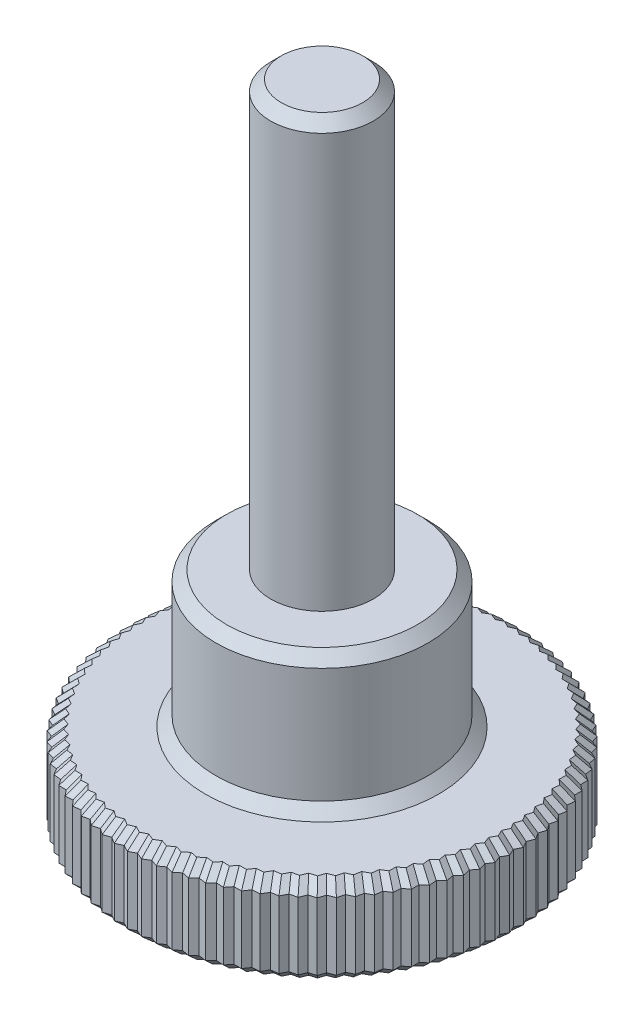
from build123d import *

# Parameters (mm, degrees)
EXTRUDE1_DEPTH = 2.5
SKETCH2_R      = 3
EXTRUDE2_DEPTH = 3.85
SKETCH3_R      = 1.45
EXTRUDE3_DEPTH = 12
CHAMFER1_SIZE  = 0.3


with BuildPart() as part:
    # Sketch1 → Extrude1 (new body)
    with BuildSketch(Plane(origin=(0, 0, 0), x_dir=(1, 0, 0), z_dir=(0, 1, 0))):
        Polygon((0, 5.5), (0.188676261, 5.402981197), (0.383660606, 5.486602276), (0.565109571, 5.376658415), (0.765452055, 5.446474378), (0.938789724, 5.324141095), (1.143514299, 5.379811804), (1.307896188, 5.245685094), (1.516005457, 5.286939328), (1.670630713, 5.141672643), (1.881110788, 5.168309414), (2.025226093, 5.012610479), (2.237051537, 5.024500017), (2.369954776, 4.859127381), (2.582093595, 4.856211761), (2.703137277, 4.681971103), (2.914555953, 4.664264529), (3.023150364, 4.482004732), (3.232818888, 4.449593469), (3.328434967, 4.260202485), (3.535331853, 4.213244437), (3.61750377, 4.017644959), (3.820621038, 3.956368902), (3.888948458, 3.755513871), (4.08729654, 3.680218335), (4.141446579, 3.475086297), (4.334059145, 3.386138114), (4.37376799, 3.177728452), (4.559706649, 3.075560969), (4.584780842, 2.864889033), (4.763139721, 2.75), (4.773457103, 2.538092163), (4.943367255, 2.411041307), (4.938877561, 2.198929963), (5.0995112, 2.060336264), (5.080236303, 1.849054797), (5.23081084, 1.699593469), (5.196844646, 1.490171223), (5.336626495, 1.330570426), (5.288134483, 1.124027683), (5.416442642, 0.955064977), (5.353661061, 0.752407994), (5.469870425, 0.574906548), (5.39310514, 0.377122649), (5.496649549, 0.191947232), (5.406274553, 0), (5.496649549, -0.191947232), (5.39310514, -0.377122649), (5.469870425, -0.574906548), (5.353661061, -0.752407994), (5.416442642, -0.955064977), (5.288134483, -1.124027683), (5.336626495, -1.330570426), (5.196844646, -1.490171223), (5.23081084, -1.699593469), (5.080236303, -1.849054797), (5.0995112, -2.060336264), (4.938877561, -2.198929963), (4.943367255, -2.411041307), (4.773457103, -2.538092163), (4.763139721, -2.75), (4.584780842, -2.864889033), (4.559706649, -3.075560969), (4.37376799, -3.177728452), (4.334059145, -3.386138114), (4.141446579, -3.475086297), (4.08729654, -3.680218335), (3.888948458, -3.755513871), (3.820621038, -3.956368902), (3.61750377, -4.017644959), (3.535331853, -4.213244437), (3.328434967, -4.260202485), (3.232818888, -4.449593469), (3.023150364, -4.482004732), (2.914555953, -4.664264529), (2.703137277, -4.681971103), (2.582093595, -4.856211761), (2.369954776, -4.859127381), (2.237051537, -5.024500017), (2.025226093, -5.012610479), (1.881110788, -5.168309414), (1.670630713, -5.141672643), (1.516005457, -5.286939328), (1.307896188, -5.245685094), (1.143514299, -5.379811804), (0.938789724, -5.324141095), (0.765452055, -5.446474378), (0.565109571, -5.376658415), (0.383660606, -5.486602276), (0.188676261, -5.402981197), (0, -5.5), (-0.188676261, -5.402981197), (-0.383660606, -5.486602276), (-0.565109571, -5.376658415), (-0.765452055, -5.446474378), (-0.938789724, -5.324141095), (-1.143514299, -5.379811804), (-1.307896188, -5.245685094), (-1.516005457, -5.286939328), (-1.670630713, -5.141672643), (-1.881110788, -5.168309414), (-2.025226093, -5.012610479), (-2.237051537, -5.024500017), (-2.369954776, -4.859127381), (-2.582093595, -4.856211761), (-2.703137277, -4.681971103), (-2.914555953, -4.664264529), (-3.023150364, -4.482004732), (-3.232818888, -4.449593469), (-3.328434967, -4.260202485), (-3.535331853, -4.213244437), (-3.61750377, -4.017644959), (-3.820621038, -3.956368902), (-3.888948458, -3.755513871), (-4.08729654, -3.680218335), (-4.141446579, -3.475086297), (-4.334059145, -3.386138114), (-4.37376799, -3.177728452), (-4.559706649, -3.075560969), (-4.584780842, -2.864889033), (-4.763139721, -2.75), (-4.773457103, -2.538092163), (-4.943367255, -2.411041307), (-4.938877561, -2.198929963), (-5.0995112, -2.060336264), (-5.080236303, -1.849054797), (-5.23081084, -1.699593469), (-5.196844646, -1.490171223), (-5.336626495, -1.330570426), (-5.288134483, -1.124027683), (-5.416442642, -0.955064977), (-5.353661061, -0.752407994), (-5.469870425, -0.574906548), (-5.39310514, -0.377122649), (-5.496649549, -0.191947232), (-5.406274553, 0), (-5.496649549, 0.191947232), (-5.39310514, 0.377122649), (-5.469870425, 0.574906548), (-5.353661061, 0.752407994), (-5.416442642, 0.955064977), (-5.288134483, 1.124027683), (-5.336626495, 1.330570426), (-5.196844646, 1.490171223), (-5.23081084, 1.699593469), (-5.080236303, 1.849054797), (-5.0995112, 2.060336264), (-4.938877561, 2.198929963), (-4.943367255, 2.411041307), (-4.773457103, 2.538092163), (-4.763139721, 2.75), (-4.584780842, 2.864889033), (-4.559706649, 3.075560969), (-4.37376799, 3.177728452), (-4.334059145, 3.386138114), (-4.141446579, 3.475086297), (-4.08729654, 3.680218335), (-3.888948458, 3.755513871), (-3.820621038, 3.956368902), (-3.61750377, 4.017644959), (-3.535331853, 4.213244437), (-3.328434967, 4.260202485), (-3.232818888, 4.449593469), (-3.023150364, 4.482004732), (-2.914555953, 4.664264529), (-2.703137277, 4.681971103), (-2.582093595, 4.856211761), (-2.369954776, 4.859127381), (-2.237051537, 5.024500017), (-2.025226093, 5.012610479), (-1.881110788, 5.168309414), (-1.670630713, 5.141672643), (-1.516005457, 5.286939328), (-1.307896188, 5.245685094), (-1.143514299, 5.379811804), (-0.938789724, 5.324141095), (-0.765452055, 5.446474378), (-0.565109571, 5.376658415), (-0.383660606, 5.486602276), (-0.188676261, 5.402981197), align=None)
    extrude(amount=EXTRUDE1_DEPTH)

    # Sketch2 → Extrude2 (add)
    with BuildSketch(Plane(origin=(0, 2.5, 0), x_dir=(1, 0, 0), z_dir=(0, 1, 0))):
        Circle(SKETCH2_R)
    extrude(amount=EXTRUDE2_DEPTH)

    # Sketch3 → Extrude3 (add)
    with BuildSketch(Plane(origin=(0, 6.35, 0), x_dir=(1, 0, 0), z_dir=(0, 1, 0))):
        Circle(SKETCH3_R)
    extrude(amount=EXTRUDE3_DEPTH)

    # Chamfer1
    chamfer1_edges = [part.edges().sort_by_distance(p)[0] for p in [
        (-3.280626927, 2.5, -4.354897977),
        (-3.43188341, 2.5, -4.236723461),
        (-0.09433813, 2.5, -5.451490598),
        (-3.576417812, 2.5, -4.115444698),
        (-3.719062404, 2.5, -3.987006931),
        (-3.854784748, 2.5, -3.855941387),
        (-3.988122499, 2.5, -3.717866103),
        (-4.11437156, 2.5, -3.577652316),
        (-4.237752862, 2.5, -3.430612206),
        (-4.353913567, 2.5, -3.281933283),
        (-4.466737319, 2.5, -3.126644711),
        (-4.572243746, 2.5, -2.970225001),
        (-4.673960281, 2.5, -2.807444517),
        (-0.286168433, 2.5, -5.444791737),
        (-4.768298412, 2.5, -2.644046082),
        (-4.858412179, 2.5, -2.474566735),
        (-4.941122408, 2.5, -2.304985635),
        (-5.01919438, 2.5, -2.129633114),
        (-5.089873752, 2.5, -1.954695531),
        (0.286168433, 0, -5.444791737),
        (0.474385088, 0, -5.431630346),
        (0.665280813, 0, -5.411566397),
        (0.85212089, 0, -5.385307736),
        (1.041152012, 0, -5.351976449),
        (1.225705244, 0, -5.312748449),
        (1.411950822, 0, -5.266312211),
        (1.593318085, 0, -5.214305985),
        (1.775870751, 0, -5.154991028),
        (-5.155523572, 2.5, -1.774324133),
        (1.953168441, 0, -5.090459947),
        (2.131138815, 0, -5.018555248),
        (2.303503156, 0, -4.941813699),
        (2.476024185, 0, -4.857669571),
        (2.642615436, 0, -4.769091432),
        (2.808846615, 0, -4.673117816),
        (2.968853159, 0, -4.57313463),
        (3.127984626, 0, -4.465799101),
        (3.280626927, 0, -4.354897977),
        (3.43188341, 0, -4.236723461),
        (-5.213827743, 2.5, -1.594882346),
        (3.576417812, 0, -4.115444698),
        (3.719062404, 0, -3.987006931),
        (3.854784748, 0, -3.855941387),
        (3.988122499, 0, -3.717866103),
        (4.11437156, 0, -3.577652316),
        (4.237752862, 0, -3.430612206),
        (4.353913567, 0, -3.281933283),
        (4.466737319, 0, -3.126644711),
        (4.572243746, 0, -2.970225001),
        (4.673960281, 0, -2.807444517),
        (-5.26673557, 2.5, -1.410370824),
        (4.768298412, 0, -2.644046082),
        (4.858412179, 0, -2.474566735),
        (4.941122408, 0, -2.304985635),
        (5.01919438, 0, -2.129633114),
        (5.089873752, 0, -1.954695531),
        (5.155523572, 0, -1.774324133),
        (5.213827743, 0, -1.594882346),
        (5.26673557, 0, -1.410370824),
        (5.312380489, 0, -1.227299055),
        (5.352288562, 0, -1.03954633),
        (-5.312380489, 2.5, -1.227299055),
        (5.385051851, 0, -0.853736486),
        (5.411765743, 0, -0.663657271),
        (5.431487782, 0, -0.476014598),
        (5.444877344, 0, -0.28453494),
        (5.451462051, 0, -0.095973616),
        (5.451462051, 0, 0.095973616),
        (5.444877344, 0, 0.28453494),
        (5.431487782, 0, 0.476014598),
        (5.411765743, 0, 0.663657271),
        (5.385051851, 0, 0.853736486),
        (-5.352288562, 2.5, -1.03954633),
        (5.352288562, 0, 1.03954633),
        (5.312380489, 0, 1.227299055),
        (5.26673557, 0, 1.410370824),
        (5.213827743, 0, 1.594882346),
        (5.155523572, 0, 1.774324133),
        (5.089873752, 0, 1.954695531),
        (5.01919438, 0, 2.129633114),
        (4.941122408, 0, 2.304985635),
        (-0.474385088, 2.5, -5.431630346),
        (4.858412179, 0, 2.474566735),
        (4.768298412, 0, 2.644046082),
        (-5.385051851, 2.5, -0.853736486),
        (4.673960281, 0, 2.807444517),
        (4.572243746, 0, 2.970225001),
        (4.466737319, 0, 3.126644711),
        (4.353913567, 0, 3.281933283),
        (4.237752862, 0, 3.430612206),
        (4.11437156, 0, 3.577652316),
        (3.988122499, 0, 3.717866103),
        (3.854784748, 0, 3.855941387),
        (3.719062404, 0, 3.987006931),
        (3.576417812, 0, 4.115444698),
        (-5.411765743, 2.5, -0.663657271),
        (3.43188341, 0, 4.236723461),
        (3.280626927, 0, 4.354897977),
        (3.127984626, 0, 4.465799101),
        (2.968853159, 0, 4.57313463),
        (2.808846615, 0, 4.673117816),
        (2.642615436, 0, 4.769091432),
        (2.476024185, 0, 4.857669571),
        (2.303503156, 0, 4.941813699),
        (2.131138815, 0, 5.018555248),
        (1.953168441, 0, 5.090459947),
        (-5.431487782, 2.5, -0.476014598),
        (1.775870751, 0, 5.154991028),
        (1.593318085, 0, 5.214305985),
        (1.411950822, 0, 5.266312211),
        (1.225705244, 0, 5.312748449),
        (1.041152012, 0, 5.351976449),
        (0.85212089, 0, 5.385307736),
        (0.665280813, 0, 5.411566397),
        (0.474385088, 0, 5.431630346),
        (0.286168433, 0, 5.444791737),
        (0.09433813, 0, 5.451490598),
        (-5.444877344, 2.5, -0.28453494),
        (-0.09433813, 0, 5.451490598),
        (-0.286168433, 0, 5.444791737),
        (-0.474385088, 0, 5.431630346),
        (-0.665280813, 0, 5.411566397),
        (-0.85212089, 0, 5.385307736),
        (-1.041152012, 0, 5.351976449),
        (-1.225705244, 0, 5.312748449),
        (-1.411950822, 0, 5.266312211),
        (-1.593318085, 0, 5.214305985),
        (-1.775870751, 0, 5.154991028),
        (-5.451462051, 2.5, -0.095973616),
        (-1.953168441, 0, 5.090459947),
        (-2.131138815, 0, 5.018555248),
        (-2.303503156, 0, 4.941813699),
        (-2.476024185, 0, 4.857669571),
        (-2.642615436, 0, 4.769091432),
        (-2.808846615, 0, 4.673117816),
        (-2.968853159, 0, 4.57313463),
        (-3.127984626, 0, 4.465799101),
        (-3.280626927, 0, 4.354897977),
        (-3.43188341, 0, 4.236723461),
        (-5.451462051, 2.5, 0.095973616),
        (-3.576417812, 0, 4.115444698),
        (-3.719062404, 0, 3.987006931),
        (-3.854784748, 0, 3.855941387),
        (-3.988122499, 0, 3.717866103),
        (-4.11437156, 0, 3.577652316),
        (-4.237752862, 0, 3.430612206),
        (-4.353913567, 0, 3.281933283),
        (-4.466737319, 0, 3.126644711),
        (-4.572243746, 0, 2.970225001),
        (-4.673960281, 0, 2.807444517),
        (-5.444877344, 2.5, 0.28453494),
        (-4.768298412, 0, 2.644046082),
        (-4.858412179, 0, 2.474566735),
        (-4.941122408, 0, 2.304985635),
        (-5.01919438, 0, 2.129633114),
        (-5.089873752, 0, 1.954695531),
        (-5.155523572, 0, 1.774324133),
        (-5.213827743, 0, 1.594882346),
        (-5.26673557, 0, 1.410370824),
        (-5.312380489, 0, 1.227299055),
        (-5.352288562, 0, 1.03954633),
        (-5.431487782, 2.5, 0.476014598),
        (-5.385051851, 0, 0.853736486),
        (-5.411765743, 0, 0.663657271),
        (-5.431487782, 0, 0.476014598),
        (-5.444877344, 0, 0.28453494),
        (-5.451462051, 0, 0.095973616),
        (-5.451462051, 0, -0.095973616),
        (-5.444877344, 0, -0.28453494),
        (-5.431487782, 0, -0.476014598),
        (-5.411765743, 0, -0.663657271),
        (-5.385051851, 0, -0.853736486),
        (-5.411765743, 2.5, 0.663657271),
        (-5.352288562, 0, -1.03954633),
        (-5.312380489, 0, -1.227299055),
        (-5.26673557, 0, -1.410370824),
        (-5.213827743, 0, -1.594882346),
        (-5.155523572, 0, -1.774324133),
        (-5.089873752, 0, -1.954695531),
        (-5.01919438, 0, -2.129633114),
        (-4.941122408, 0, -2.304985635),
        (-4.858412179, 0, -2.474566735),
        (-4.768298412, 0, -2.644046082),
        (-5.385051851, 2.5, 0.853736486),
        (-4.673960281, 0, -2.807444517),
        (-4.572243746, 0, -2.970225001),
        (-4.466737319, 0, -3.126644711),
        (-4.353913567, 0, -3.281933283),
        (-4.237752862, 0, -3.430612206),
        (-4.11437156, 0, -3.577652316),
        (-3.988122499, 0, -3.717866103),
        (-3.854784748, 0, -3.855941387),
        (-0.665280813, 2.5, -5.411566397),
        (-3.719062404, 0, -3.987006931),
        (-3.576417812, 0, -4.115444698),
        (-5.352288562, 2.5, 1.03954633),
        (-3.43188341, 0, -4.236723461),
        (-3.280626927, 0, -4.354897977),
        (-3.127984626, 0, -4.465799101),
        (-2.968853159, 0, -4.57313463),
        (-2.808846615, 0, -4.673117816),
        (-2.642615436, 0, -4.769091432),
        (-2.476024185, 0, -4.857669571),
        (-2.303503156, 0, -4.941813699),
        (-2.131138815, 0, -5.018555248),
        (-1.953168441, 0, -5.090459947),
        (-5.312380489, 2.5, 1.227299055),
        (-1.775870751, 0, -5.154991028),
        (-1.593318085, 0, -5.214305985),
        (-1.411950822, 0, -5.266312211),
        (-1.225705244, 0, -5.312748449),
        (-1.041152012, 0, -5.351976449),
        (-0.85212089, 0, -5.385307736),
        (-0.665280813, 0, -5.411566397),
        (-0.474385088, 0, -5.431630346),
        (-0.286168433, 0, -5.444791737),
        (-0.09433813, 0, -5.451490598),
        (-5.26673557, 2.5, 1.410370824),
        (0.09433813, 0, -5.451490598),
        (-5.213827743, 2.5, 1.594882346),
        (-5.155523572, 2.5, 1.774324133),
        (-5.089873752, 2.5, 1.954695531),
        (-5.01919438, 2.5, 2.129633114),
        (-4.941122408, 2.5, 2.304985635),
        (-4.858412179, 2.5, 2.474566735),
        (-4.768298412, 2.5, 2.644046082),
        (-0.85212089, 2.5, -5.385307736),
        (-4.673960281, 2.5, 2.807444517),
        (-4.572243746, 2.5, 2.970225001),
        (-4.466737319, 2.5, 3.126644711),
        (-4.353913567, 2.5, 3.281933283),
        (-4.237752862, 2.5, 3.430612206),
        (-4.11437156, 2.5, 3.577652316),
        (-3.988122499, 2.5, 3.717866103),
        (-3.854784748, 2.5, 3.855941387),
        (-3.719062404, 2.5, 3.987006931),
        (-3.576417812, 2.5, 4.115444698),
        (-1.041152012, 2.5, -5.351976449),
        (-3.43188341, 2.5, 4.236723461),
        (-3.280626927, 2.5, 4.354897977),
        (-3.127984626, 2.5, 4.465799101),
        (-2.968853159, 2.5, 4.57313463),
        (-2.808846615, 2.5, 4.673117816),
        (-2.642615436, 2.5, 4.769091432),
        (-2.476024185, 2.5, 4.857669571),
        (-2.303503156, 2.5, 4.941813699),
        (-2.131138815, 2.5, 5.018555248),
        (-1.953168441, 2.5, 5.090459947),
        (-1.225705244, 2.5, -5.312748449),
        (-1.775870751, 2.5, 5.154991028),
        (-1.593318085, 2.5, 5.214305985),
        (-1.411950822, 2.5, 5.266312211),
        (-1.225705244, 2.5, 5.312748449),
        (-1.041152012, 2.5, 5.351976449),
        (-0.85212089, 2.5, 5.385307736),
        (-0.665280813, 2.5, 5.411566397),
        (-0.474385088, 2.5, 5.431630346),
        (-0.286168433, 2.5, 5.444791737),
        (-0.09433813, 2.5, 5.451490598),
        (-1.411950822, 2.5, -5.266312211),
        (0.09433813, 2.5, 5.451490598),
        (0.286168433, 2.5, 5.444791737),
        (0.474385088, 2.5, 5.431630346),
        (0.665280813, 2.5, 5.411566397),
        (0.85212089, 2.5, 5.385307736),
        (1.041152012, 2.5, 5.351976449),
        (1.225705244, 2.5, 5.312748449),
        (1.411950822, 2.5, 5.266312211),
        (1.593318085, 2.5, 5.214305985),
        (1.775870751, 2.5, 5.154991028),
        (-1.593318085, 2.5, -5.214305985),
        (1.953168441, 2.5, 5.090459947),
        (2.131138815, 2.5, 5.018555248),
        (2.303503156, 2.5, 4.941813699),
        (2.476024185, 2.5, 4.857669571),
        (-3, 2.5, 0),
        (-3, 6.35, 0),
        (2.642615436, 2.5, 4.769091432),
        (-1.45, 18.35, 0),
        (2.808846615, 2.5, 4.673117816),
        (2.968853159, 2.5, 4.57313463),
        (3.127984626, 2.5, 4.465799101),
        (3.280626927, 2.5, 4.354897977),
        (3.43188341, 2.5, 4.236723461),
        (-1.775870751, 2.5, -5.154991028),
        (3.576417812, 2.5, 4.115444698),
        (3.719062404, 2.5, 3.987006931),
        (3.854784748, 2.5, 3.855941387),
        (3.988122499, 2.5, 3.717866103),
        (4.11437156, 2.5, 3.577652316),
        (4.237752862, 2.5, 3.430612206),
        (4.353913567, 2.5, 3.281933283),
        (4.466737319, 2.5, 3.126644711),
        (0.09433813, 2.5, -5.451490598),
        (4.572243746, 2.5, 2.970225001),
        (4.673960281, 2.5, 2.807444517),
        (-1.953168441, 2.5, -5.090459947),
        (4.768298412, 2.5, 2.644046082),
        (4.858412179, 2.5, 2.474566735),
        (4.941122408, 2.5, 2.304985635),
        (5.01919438, 2.5, 2.129633114),
        (5.089873752, 2.5, 1.954695531),
        (5.155523572, 2.5, 1.774324133),
        (5.213827743, 2.5, 1.594882346),
        (5.26673557, 2.5, 1.410370824),
        (5.312380489, 2.5, 1.227299055),
        (5.352288562, 2.5, 1.03954633),
        (-2.131138815, 2.5, -5.018555248),
        (5.385051851, 2.5, 0.853736486),
        (5.411765743, 2.5, 0.663657271),
        (5.431487782, 2.5, 0.476014598),
        (5.444877344, 2.5, 0.28453494),
        (5.451462051, 2.5, 0.095973616),
        (5.451462051, 2.5, -0.095973616),
        (5.444877344, 2.5, -0.28453494),
        (5.431487782, 2.5, -0.476014598),
        (5.411765743, 2.5, -0.663657271),
        (5.385051851, 2.5, -0.853736486),
        (-2.303503156, 2.5, -4.941813699),
        (5.352288562, 2.5, -1.03954633),
        (5.312380489, 2.5, -1.227299055),
        (5.26673557, 2.5, -1.410370824),
        (5.213827743, 2.5, -1.594882346),
        (5.155523572, 2.5, -1.774324133),
        (5.089873752, 2.5, -1.954695531),
        (5.01919438, 2.5, -2.129633114),
        (4.941122408, 2.5, -2.304985635),
        (4.858412179, 2.5, -2.474566735),
        (4.768298412, 2.5, -2.644046082),
        (-2.476024185, 2.5, -4.857669571),
        (4.673960281, 2.5, -2.807444517),
        (4.572243746, 2.5, -2.970225001),
        (4.466737319, 2.5, -3.126644711),
        (4.353913567, 2.5, -3.281933283),
        (4.237752862, 2.5, -3.430612206),
        (4.11437156, 2.5, -3.577652316),
        (3.988122499, 2.5, -3.717866103),
        (3.854784748, 2.5, -3.855941387),
        (3.719062404, 2.5, -3.987006931),
        (3.576417812, 2.5, -4.115444698),
        (-2.642615436, 2.5, -4.769091432),
        (3.43188341, 2.5, -4.236723461),
        (3.280626927, 2.5, -4.354897977),
        (3.127984626, 2.5, -4.465799101),
        (2.968853159, 2.5, -4.57313463),
        (2.808846615, 2.5, -4.673117816),
        (2.642615436, 2.5, -4.769091432),
        (2.476024185, 2.5, -4.857669571),
        (2.303503156, 2.5, -4.941813699),
        (2.131138815, 2.5, -5.018555248),
        (1.953168441, 2.5, -5.090459947),
        (-2.808846615, 2.5, -4.673117816),
        (1.775870751, 2.5, -5.154991028),
        (1.593318085, 2.5, -5.214305985),
        (1.411950822, 2.5, -5.266312211),
        (1.225705244, 2.5, -5.312748449),
        (1.041152012, 2.5, -5.351976449),
        (0.85212089, 2.5, -5.385307736),
        (0.665280813, 2.5, -5.411566397),
        (0.474385088, 2.5, -5.431630346),
        (0.286168433, 2.5, -5.444791737),
        (-2.968853159, 2.5, -4.57313463),
        (-3.127984626, 2.5, -4.465799101),
    ]]
    chamfer(chamfer1_edges, length=CHAMFER1_SIZE)


solid = part.part
